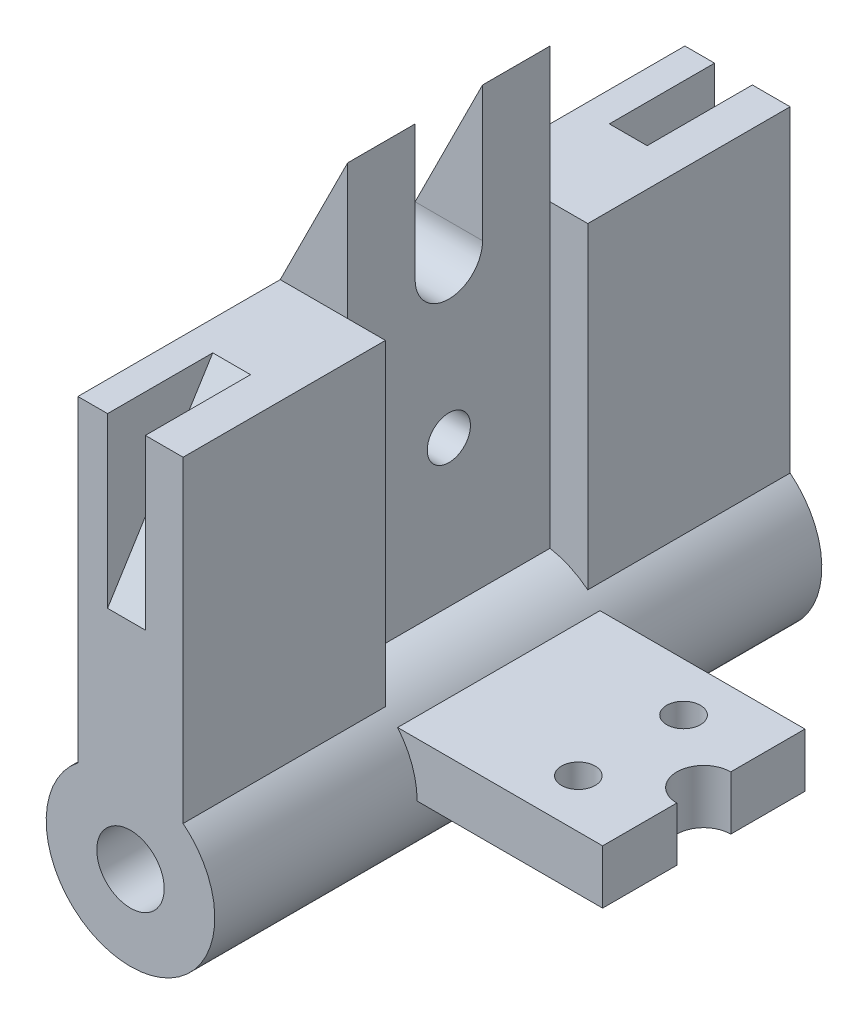
from build123d import *
from build123d.topology import SkipClean

# Parameters (mm, degrees)
SKETCH1_R           = 15.875
SKETCH1_R_2         = 6.35
BOSS_EXTRUDE1_DEPTH = 19.05
BOSS_EXTRUDE2_START = 19.05
SKETCH1_3_R         = 15.875
SKETCH1_3_R_2       = 6.35
BOSS_EXTRUDE2_DEPTH = 38.1
BOSS_EXTRUDE3_START = -19.05
SKETCH1_4_R         = 15.875
SKETCH1_4_R_2       = 6.35
BOSS_EXTRUDE3_DEPTH = 38.1
SKETCH2_W           = 7.112
SKETCH2_H           = 19.812
CUT_EXTRUDE1_DEPTH  = 138.602767
SKETCH4_R           = 6.35
SKETCH4_R_2         = 4.064
CUT_EXTRUDE2_DEPTH  = 123.816814
SKETCH5_R           = 3.175
SKETCH5_R_2         = 5.08
CUT_EXTRUDE3_DEPTH  = 117.109121


with BuildPart() as part:
    # Sketch1 → Boss-Extrude1 (new, symmetric)
    with BuildSketch(Plane.XY):
        Polygon((2.794, 97.536), (-9.906, 72.136), (0, 72.136), (2.794, 72.136), align=None)
        with BuildLine():
            Line((-9.906, 72.136), (-9.906, 12.405111))
            ThreePointArc((-9.906, 12.405111), (-5.24807, 14.982436), (0, 15.875))
            Line((0, 15.875), (0, 72.136))
            Line((0, 72.136), (-9.906, 72.136))
        make_face()
        with BuildLine():
            Line((0, 72.136), (0, 15.875))
            ThreePointArc((0, 15.875), (1.402484, 15.812927), (2.794, 15.627194))
            Line((2.794, 15.627194), (2.794, 72.136))
            Line((2.794, 72.136), (0, 72.136))
        make_face()
        Circle(SKETCH1_R)
        with Locations(Location((0, 0, 0), (0, 0, 180))):
            Circle(SKETCH1_R_2, mode=Mode.SUBTRACT)
        with BuildLine():
            ThreePointArc((12.197952, 10.16), (14.92746, 5.40246), (15.875, 0))
            Line((15.875, 0), (50.8, 0))
            Line((50.8, 0), (50.8, 10.16))
            Line((50.8, 10.16), (12.197952, 10.16))
        make_face()
    extrude(amount=BOSS_EXTRUDE1_DEPTH, both=True)

    # Sketch1_3 → Boss-Extrude2 (add)
    with BuildSketch(Plane.XY.offset(BOSS_EXTRUDE2_START)):
        with BuildLine():
            Line((-9.906, 72.136), (-9.906, 12.405111))
            ThreePointArc((-9.906, 12.405111), (-5.24807, 14.982436), (0, 15.875))
            Line((0, 15.875), (0, 72.136))
            Line((0, 72.136), (-9.906, 72.136))
        make_face()
        Circle(SKETCH1_3_R)
        with Locations(Location((0, 0, 0), (0, 0, 180))):
            Circle(SKETCH1_3_R_2, mode=Mode.SUBTRACT)
        with BuildLine():
            ThreePointArc((2.794, 15.627194), (6.55118, 14.46021), (9.906, 12.405111))
            Line((9.906, 12.405111), (9.906, 72.136))
            Line((9.906, 72.136), (2.794, 72.136))
            Line((2.794, 72.136), (2.794, 15.627194))
        make_face()
        with BuildLine():
            Line((0, 72.136), (0, 15.875))
            ThreePointArc((0, 15.875), (1.402484, 15.812927), (2.794, 15.627194))
            Line((2.794, 15.627194), (2.794, 72.136))
            Line((2.794, 72.136), (0, 72.136))
        make_face()
    extrude(amount=BOSS_EXTRUDE2_DEPTH)

    # Sketch1_4 → Boss-Extrude3 (add)
    with SkipClean():  # the faces are left unmerged after this step: merging them gives an invalid solid
        with BuildSketch(Plane.XY.offset(BOSS_EXTRUDE3_START)):
            with BuildLine():
                ThreePointArc((2.794, 15.627194), (6.55118, 14.46021), (9.906, 12.405111))
                Line((9.906, 12.405111), (9.906, 72.136))
                Line((9.906, 72.136), (2.794, 72.136))
                Line((2.794, 72.136), (2.794, 15.627194))
            make_face()
            with BuildLine():
                Line((-9.906, 72.136), (-9.906, 12.405111))
                ThreePointArc((-9.906, 12.405111), (-5.24807, 14.982436), (0, 15.875))
                Line((0, 15.875), (0, 72.136))
                Line((0, 72.136), (-9.906, 72.136))
            make_face()
            Circle(SKETCH1_4_R)
            with Locations(Location((0, 0, 0), (0, 0, 180))):
                Circle(SKETCH1_4_R_2, mode=Mode.SUBTRACT)
            with BuildLine():
                Line((0, 72.136), (0, 15.875))
                ThreePointArc((0, 15.875), (1.402484, 15.812927), (2.794, 15.627194))
                Line((2.794, 15.627194), (2.794, 72.136))
                Line((2.794, 72.136), (0, 72.136))
            make_face()
        extrude(amount=-BOSS_EXTRUDE3_DEPTH)

    # Sketch2 → Cut-Extrude1 (cut, through all, along a direction that is not the sketch's normal)
    with SkipClean():  # the faces are left unmerged after this step: merging them gives an invalid solid
        with BuildSketch(Plane(origin=(0, 72.136, 0), x_dir=(1, 0, 0), z_dir=(0, 1, 0))):
            with Locations((-0.762, -47.244)):
                Rectangle(SKETCH2_W, SKETCH2_H)
        cut_extrude1 = extrude(amount=-CUT_EXTRUDE1_DEPTH, dir=(0, 0.8483793786580408, -0.5293887322826173), mode=Mode.SUBTRACT)

    # Mirror1: Cut-Extrude1 across plane
    with SkipClean():  # the faces are left unmerged after this step: merging them gives an invalid solid
        add(cut_extrude1.mirror(Plane.XY), mode=Mode.SUBTRACT)

    # Sketch4 → Cut-Extrude2 (cut, through all)
    with SkipClean():  # the faces are left unmerged after this step: merging them gives an invalid solid
        with BuildSketch(Plane(origin=(2.794, 0, 0), x_dir=(0, 0, -1), z_dir=(1, 0, 0))):
            with BuildLine():
                Line((-6.35, 97.536), (-6.35, 72.136))
                ThreePointArc((-6.35, 72.136), (0, 78.486), (6.35, 72.136))
                Line((6.35, 72.136), (6.35, 97.536))
                Line((6.35, 97.536), (-6.35, 97.536))
            make_face()
            with Locations((0, 72.136)):
                Circle(SKETCH4_R)
            with Locations((0, 43.18)):
                Circle(SKETCH4_R_2)
        extrude(amount=-CUT_EXTRUDE2_DEPTH, mode=Mode.SUBTRACT)

    # Sketch5 → Cut-Extrude3 (cut, through all)
    with SkipClean():  # the faces are left unmerged after this step: merging them gives an invalid solid
        with BuildSketch(Plane(origin=(0, 10.16, 0), x_dir=(1, 0, 0), z_dir=(0, 1, 0))):
            with Locations(Location((37.084, -9.906, 0), (0, 0, 180))):
                Circle(SKETCH5_R)
            with Locations(Location((37.084, 9.906, 0), (0, 0, 180))):
                Circle(SKETCH5_R)
            with Locations((50.8, 0)):
                Circle(SKETCH5_R_2)
        extrude(amount=-CUT_EXTRUDE3_DEPTH, mode=Mode.SUBTRACT)


solid = part.part
